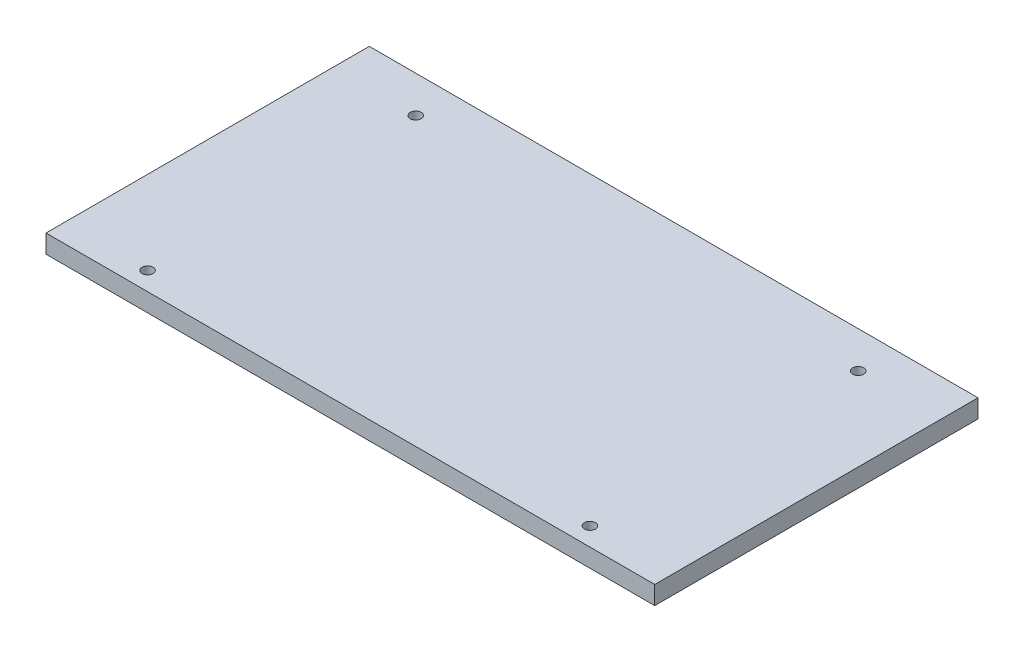
from build123d import *

# Parameters (mm, degrees)
SKETCH1_W           = 155.702807198
SKETCH1_H           = 58
SKETCH1_R           = 1.5
BOSS_EXTRUDE2_DEPTH = 5
SKETCH2_W           = 5
SKETCH2_H           = 88
BOSS_EXTRUDE3_DEPTH = 5


with BuildPart() as part:
    # Sketch1 → Boss-Extrude2 (new body)
    with BuildSketch(Plane(origin=(0, 0, 0), x_dir=(1, 0, 0), z_dir=(0, 1, 0))):
        with Locations((1.171695753, -5)):
            Rectangle(SKETCH1_W, SKETCH1_H)
        Polygon((-76.679707846, 44), (-76.679707846, 24), (79.023099352, 24), (79.023099352, 44), (62.885457038, 44), (59.885457038, 44), (-57.542065533, 44), (-60.542065533, 44), align=None)
        with Locations((-59.042065533, 34)):
            Circle(SKETCH1_R, mode=Mode.SUBTRACT)
        with Locations((61.385457038, 34)):
            Circle(SKETCH1_R, mode=Mode.SUBTRACT)
        Polygon((-76.679707846, -44), (-60.542065533, -44), (-57.542065533, -44), (59.885457038, -44), (62.885457038, -44), (79.023099352, -44), (79.023099352, -34), (-76.679707846, -34), align=None)
        with Locations((-59.042065533, -39)):
            Circle(SKETCH1_R, mode=Mode.SUBTRACT)
        with Locations((61.385457038, -39)):
            Circle(SKETCH1_R, mode=Mode.SUBTRACT)
    extrude(amount=BOSS_EXTRUDE2_DEPTH)

    # Sketch2 → Boss-Extrude3 (add)
    with BuildSketch(Plane(origin=(0, 5, 0), x_dir=(1, 0, 0), z_dir=(0, 1, 0))):
        with Locations((81.523099352, 0)):
            Rectangle(SKETCH2_W, SKETCH2_H)
        with Locations((-79.179707846, 0)):
            Rectangle(SKETCH2_W, SKETCH2_H)
    extrude(amount=-BOSS_EXTRUDE3_DEPTH)


solid = part.part
